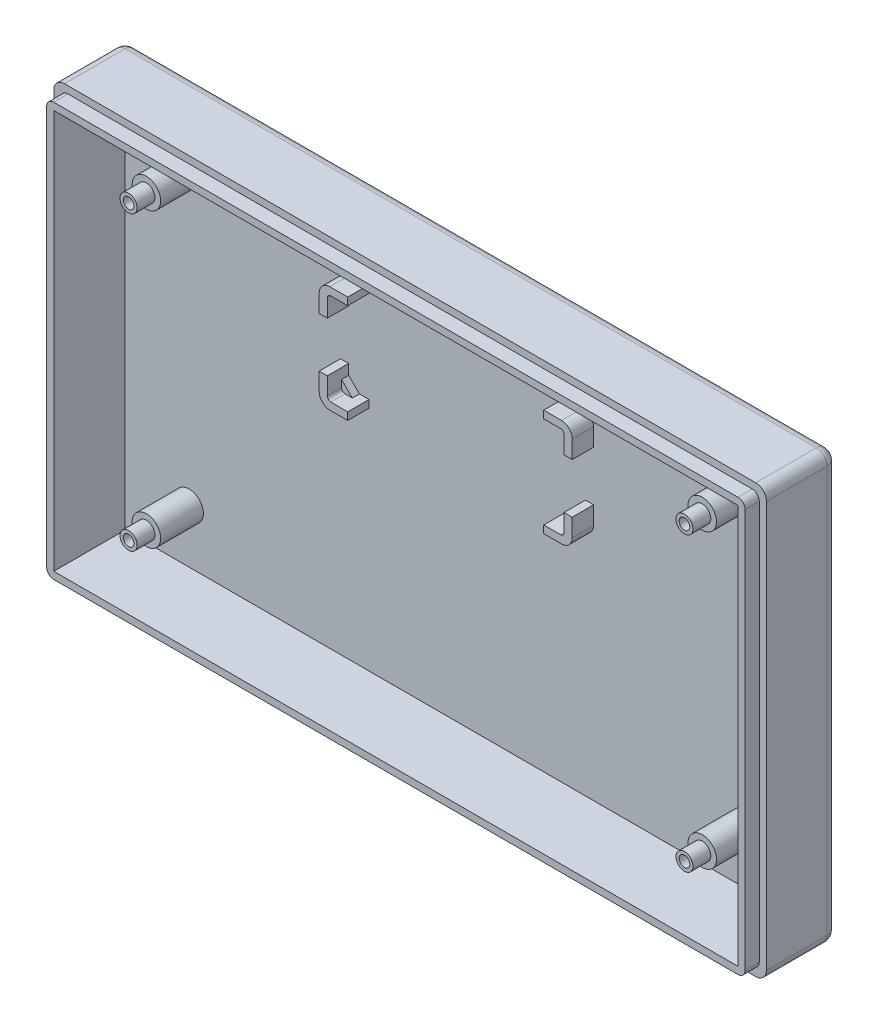
from build123d import *

# Parameters (mm, degrees)
SKETCH_1_W                  = 100
SKETCH_1_H                  = 60
EXTRUDE_1_DEPTH             = 2
SKETCH_2_W                  = 96
SKETCH_2_H                  = 56
EXTRUDE_2_DEPTH             = 10
SKETCH_3_W                  = 100
SKETCH_3_H                  = 60
SKETCH_3_W_2                = 98
SKETCH_3_H_2                = 58
CUT_EXTRUDE_1_DEPTH         = 2
EXTRUDE_3_DEPTH             = 3
EXTRUDE_4_DEPTH             = 1
FILLET_1_R                  = 0.5
FILLET_2_R                  = 1.5
SKETCH_6_R                  = 2
EXTRUDE_5_DEPTH             = 6
SKETCH_7_R                  = 1.2
EXTRUDE_6_DEPTH             = 2.5
SKETCH_8_R                  = 0.75
CUT_EXTRUDE_2_DEPTH         = 12.5
FILLET_3_R                  = 1.5
FILLET_4_R                  = 1.5
FILLET_5_R                  = 1
SKETCH_9_R                  = 1.5
CUT_EXTRUDE_3_DEPTH         = 7
PATTERN_LINEAR_1_COUNT      = 2
PATTERN_LINEAR_1_PITCH      = 78
PATTERN_LINEAR_1_COUNT_DIR2 = 2
PATTERN_LINEAR_1_PITCH_DIR2 = 41


with BuildPart() as part:
    # 草图1 → 凸台-拉伸1 (new body)
    with BuildSketch(Plane.XY):
        Rectangle(SKETCH_1_W, SKETCH_1_H)
    extrude(amount=EXTRUDE_1_DEPTH)

    # 草图2 → 凸台-拉伸2 (add)
    with BuildSketch(Plane.XY.offset(2)):
        Polygon((-47, 30), (-50, 30), (-50, 27), (-50, -27), (-50, -30), (-47, -30), (47, -30), (50, -30), (50, -27), (50, 27), (50, 30), (47, 30), align=None)
        Rectangle(SKETCH_2_W, SKETCH_2_H, mode=Mode.SUBTRACT)
    extrude(amount=EXTRUDE_2_DEPTH)

    # 草图3 → 切除-拉伸1 (cut)
    with BuildSketch(Plane.XY.offset(12)):
        Rectangle(SKETCH_3_W, SKETCH_3_H)
        Rectangle(SKETCH_3_W_2, SKETCH_3_H_2, mode=Mode.SUBTRACT)
    extrude(amount=-CUT_EXTRUDE_1_DEPTH, mode=Mode.SUBTRACT)

    # 草图4 → 凸台-拉伸3 (add)
    with BuildSketch(Plane.XY.offset(2)):
        Polygon((-16.61, 17.9), (-13.75, 17.9), (-13.75, 18.95), (-17.75, 18.95), (-17.75, 14.95), (-16.61, 14.95), align=None)
        Polygon((-16.61, 5), (-13.75, 5), (-13.75, 3.95), (-17.75, 3.95), (-17.75, 7.95), (-16.61, 7.95), align=None)
        Polygon((16.61, 17.9), (16.61, 14.95), (17.75, 14.95), (17.75, 18.95), (13.75, 18.95), (13.75, 17.9), align=None)
        Polygon((17.75, 3.95), (13.75, 3.95), (13.75, 5), (16.61, 5), (16.61, 7.95), (17.75, 7.95), align=None)
    extrude(amount=EXTRUDE_3_DEPTH)

    # 草图5 → 凸台-拉伸4 (add)
    with BuildSketch(Plane.XY.offset(2)):
        Polygon((-16.61, 17.9), (-15.11, 17.9), (-16.61, 16.4), align=None)
        Polygon((16.61, 17.9), (15.11, 17.9), (16.61, 16.4), align=None)
        Polygon((16.61, 5), (16.61, 6.5), (15.11, 5), align=None)
        Polygon((-16.61, 5), (-15.11, 5), (-16.61, 6.5), align=None)
    extrude(amount=EXTRUDE_4_DEPTH)

    # 圆角1
    fillet_1_edges = [part.edges().sort_by_distance(p)[0] for p in [
        (-16.61, 5, 4),
        (16.61, 17.9, 4),
        (-16.61, 17.9, 4),
        (16.61, 5, 4),
    ]]
    fillet(fillet_1_edges, radius=FILLET_1_R)

    # 圆角2
    fillet_2_edges = [part.edges().sort_by_distance(p)[0] for p in [
        (-17.75, 3.95, 3.5),
        (17.75, 18.95, 3.5),
        (-17.75, 18.95, 3.5),
        (17.75, 3.95, 3.5),
    ]]
    fillet(fillet_2_edges, radius=FILLET_2_R)

    # 草图6 → 凸台-拉伸5 (add)
    with BuildSketch(Plane.XY.offset(2)):
        with Locations((-39, 20.5)):
            Circle(SKETCH_6_R)
        with Locations((39, 20.5)):
            Circle(SKETCH_6_R)
        with Locations((39, -20.5)):
            Circle(SKETCH_6_R)
        with Locations((-39, -20.5)):
            Circle(SKETCH_6_R)
    extrude(amount=EXTRUDE_5_DEPTH)

    # 草图7 → 凸台-拉伸6 (add)
    with BuildSketch(Plane.XY.offset(8)):
        with Locations((-39, 20.5)):
            Circle(SKETCH_7_R)
        with Locations((39, 20.5)):
            Circle(SKETCH_7_R)
        with Locations((39, -20.5)):
            Circle(SKETCH_7_R)
        with Locations((-39, -20.5)):
            Circle(SKETCH_7_R)
    extrude(amount=EXTRUDE_6_DEPTH)

    # 草图8 → 切除-拉伸2 (cut)
    with BuildSketch(Plane.XY.offset(10.5)):
        with Locations((-39, 20.5)):
            Circle(SKETCH_8_R)
        with Locations((-39, -20.5)):
            Circle(SKETCH_8_R)
        with Locations((39, -20.5)):
            Circle(SKETCH_8_R)
        with Locations((39, 20.5)):
            Circle(SKETCH_8_R)
    extrude(amount=-CUT_EXTRUDE_2_DEPTH, mode=Mode.SUBTRACT)

    # 圆角3
    fillet_3_edges = [part.edges().sort_by_distance(p)[0] for p in [
        (-50, 30, 5),
        (50, 30, 5),
        (50, -30, 5),
        (-50, -30, 5),
    ]]
    fillet(fillet_3_edges, radius=FILLET_3_R)

    # 圆角4
    fillet_4_edges = [part.edges().sort_by_distance(p)[0] for p in [
        (0, 30, 0),
        (-50, 0, 0),
        (50, 0, 0),
        (0, -30, 0),
        (-49.560660172, 29.560660172, 0),
        (-49.560660172, -29.560660172, 0),
        (49.560660172, -29.560660172, 0),
        (49.560660172, 29.560660172, 0),
    ]]
    fillet(fillet_4_edges, radius=FILLET_4_R)

    # 圆角5
    fillet_5_edges = [part.edges().sort_by_distance(p)[0] for p in [
        (-49, 29, 11),
        (49, 29, 11),
        (49, -29, 11),
        (-49, -29, 11),
    ]]
    fillet(fillet_5_edges, radius=FILLET_5_R)

    # 草图9 → 切除-拉伸3 (cut)
    with BuildSketch(Plane(origin=(0, 0, 0), x_dir=(-1, 0, 0), z_dir=(0, 0, -1))):
        with Locations((-39, 20.5)):
            Circle(SKETCH_9_R)
    cut_extrude_3 = extrude(amount=-CUT_EXTRUDE_3_DEPTH, mode=Mode.SUBTRACT)

    # 阵列(线性)1: Cut-Extrude 3 2 × 2
    with Locations(*[(-i * PATTERN_LINEAR_1_PITCH, -j * PATTERN_LINEAR_1_PITCH_DIR2, 0) for i in range(PATTERN_LINEAR_1_COUNT) for j in range(PATTERN_LINEAR_1_COUNT_DIR2) if (i, j) != (0, 0)]):
        add(cut_extrude_3, mode=Mode.SUBTRACT)


solid = part.part
